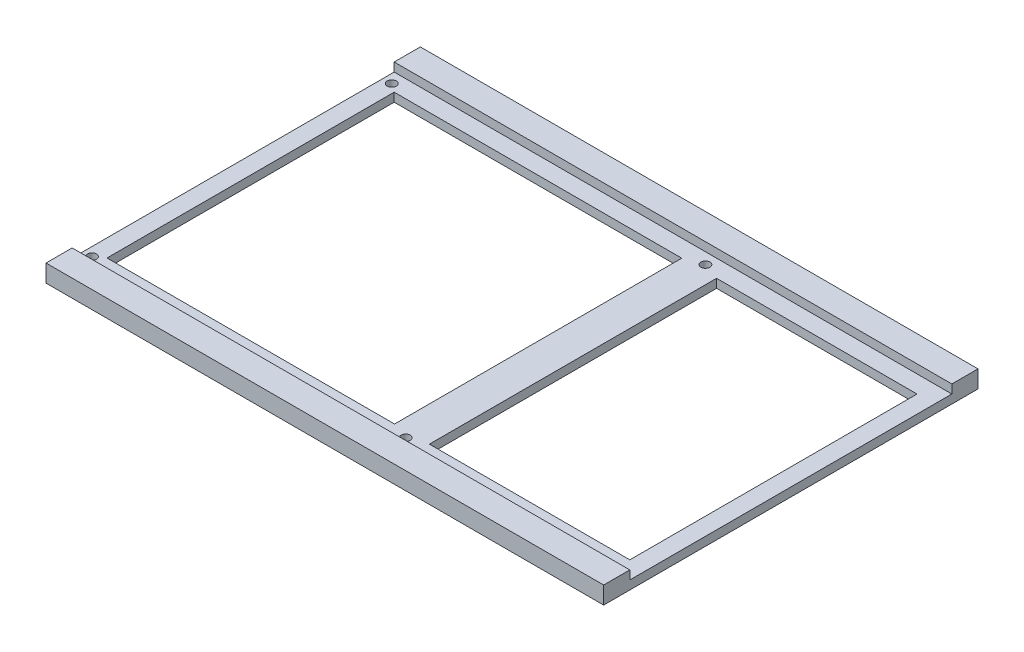
from build123d import *

# Parameters (mm, degrees)
SKETCH1_W                 = 203.2
SKETCH1_H                 = 136.398
BOSS_EXTRUDE1_DEPTH       = 6.35
SKETCH3_W                 = 117.348
SKETCH3_H                 = 3.175
CUT_EXTRUDE1_DEPTH        = 204.2
SKETCH4_W                 = 104.775
SKETCH4_H                 = 104.648
SKETCH4_W_2               = 73.025
CUT_EXTRUDE3_DEPTH        = 4.175
M4X0_7_TAPPED_HOLE1_D     = 3.3
M4X0_7_TAPPED_HOLE1_DEPTH = 9.906


with BuildPart() as part:
    # Sketch1 → Boss-Extrude1 (new body)
    with BuildSketch(Plane(origin=(0, 0, 0), x_dir=(1, 0, 0), z_dir=(0, 1, 0))):
        Rectangle(SKETCH1_W, SKETCH1_H)
    extrude(amount=BOSS_EXTRUDE1_DEPTH)

    # Sketch3 → Cut-Extrude1 (cut, through all)
    with BuildSketch(Plane(origin=(101.6, 0, 0), x_dir=(0, 0, -1), z_dir=(1, 0, 0))):
        with Locations((0, 4.7625)):
            Rectangle(SKETCH3_W, SKETCH3_H)
    extrude(amount=-CUT_EXTRUDE1_DEPTH, mode=Mode.SUBTRACT)

    # Sketch4 → Cut-Extrude3 (cut, through all)
    with BuildSketch(Plane(origin=(0, 3.175, 0), x_dir=(1, 0, 0), z_dir=(0, 1, 0))):
        with Locations((-42.8625, 0)):
            Rectangle(SKETCH4_W, SKETCH4_H)
        with Locations((58.7375, 0)):
            Rectangle(SKETCH4_W_2, SKETCH4_H)
    extrude(amount=-CUT_EXTRUDE3_DEPTH, mode=Mode.SUBTRACT)

    # M4x0.7 Tapped Hole1
    with Locations(Plane(origin=(0, 3.175, 0), x_dir=(1, 0, 0), z_dir=(0, 1, 0))):
        with Locations((-98.425, -54.61), (-98.425, 54.61), (15.875, 54.61), (15.875, -54.61)):
            Hole(M4X0_7_TAPPED_HOLE1_D / 2, depth=M4X0_7_TAPPED_HOLE1_DEPTH)


solid = part.part
